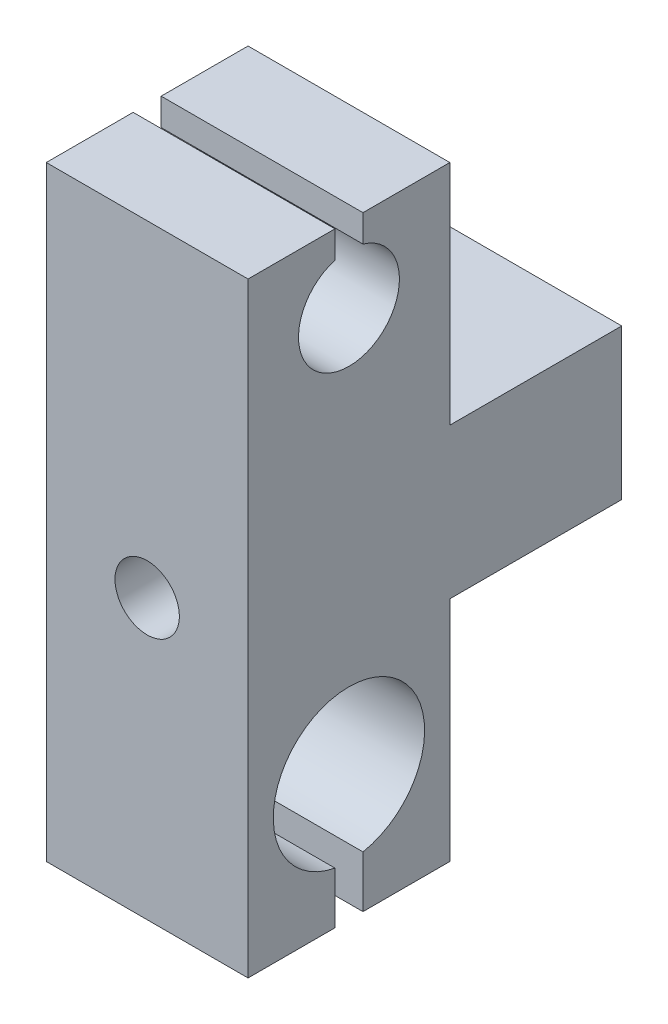
from build123d import *

# Parameters (mm, degrees)
BOSS_EXTRUDE1_DEPTH = 25.4
SKETCH3_R           = 4.05
CUT_EXTRUDE1_DEPTH  = 48.0377


with BuildPart() as part:
    # Sketch1 → Boss-Extrude1 (new body)
    with BuildSketch(Plane(origin=(0, 0, 0), x_dir=(0, 0, -1), z_dir=(1, 0, 0))):
        with BuildLine():
            Line((-1.764817843, 38.1), (-1.764817843, 34.67482934))
            ThreePointArc((-1.764817843, 34.67482934), (0, 22.225), (1.764817843, 34.67482934))
            Line((1.764817843, 34.67482934), (1.764817843, 38.1))
            Line((1.764817843, 38.1), (12.7, 38.1))
            Line((12.7, 38.1), (12.7, 9.46650416))
            Line((12.7, 9.46650416), (34.3377, 9.46650416))
            Line((34.3377, 9.46650416), (34.3377, -9.46650416))
            Line((34.3377, -9.46650416), (12.7, -9.46650416))
            Line((12.7, -9.46650416), (12.7, -38.1))
            Line((12.7, -38.1), (1.764817843, -38.1))
            Line((1.764817843, -38.1), (1.764817843, -31.585077082))
            ThreePointArc((1.764817843, -31.585077082), (0, -12.7), (-1.764817843, -31.585077082))
            Line((-1.764817843, -31.585077082), (-1.764817843, -38.1))
            Line((-1.764817843, -38.1), (-12.7, -38.1))
            Line((-12.7, -38.1), (-12.7, 38.1))
            Line((-12.7, 38.1), (-1.764817843, 38.1))
        make_face()
    extrude(amount=BOSS_EXTRUDE1_DEPTH)

    # Sketch3 → Cut-Extrude1 (cut, through all)
    with BuildSketch(Plane(origin=(0, 0, -34.3377), x_dir=(-1, 0, 0), z_dir=(0, 0, -1))):
        with Locations((-12.7, -3.002772529)):
            Circle(SKETCH3_R)
    extrude(amount=-CUT_EXTRUDE1_DEPTH, mode=Mode.SUBTRACT)


solid = part.part
